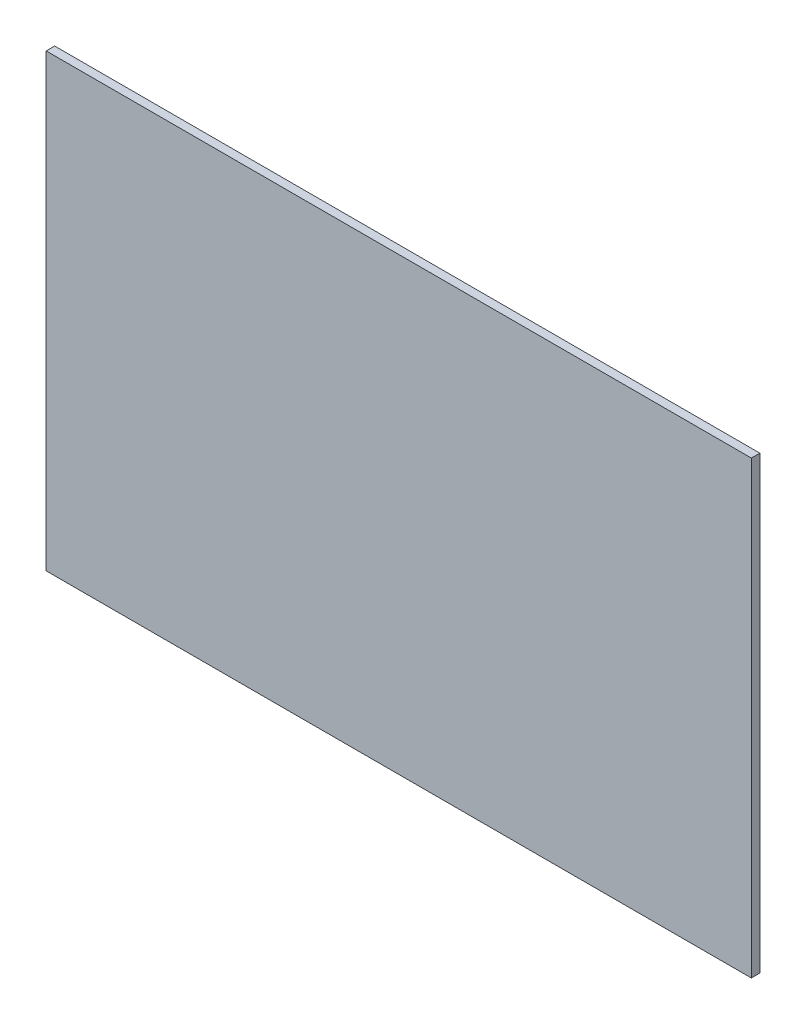
from build123d import *

# Parameters (mm, degrees)
SKETCH1_W          = 166
SKETCH1_H          = 106
DIFFUSEPLATE_DEPTH = 2


with BuildPart() as part:
    # Sketch1 → DiffusePlate (new body)
    with BuildSketch(Plane.XY):
        Rectangle(SKETCH1_W, SKETCH1_H)
    extrude(amount=DIFFUSEPLATE_DEPTH)


solid = part.part
